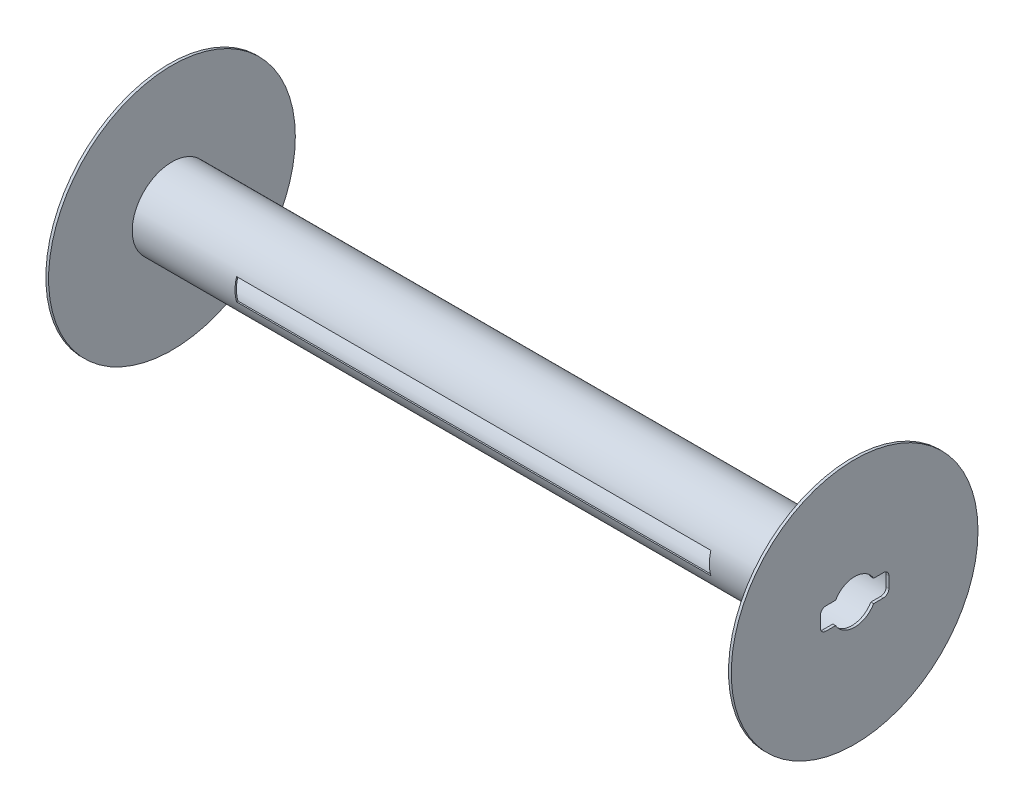
from build123d import *

# Parameters (mm, degrees)
SKETCH1_R           = 11.43
BOSS_EXTRUDE1_DEPTH = 0.254
SKETCH2_R           = 3.683
SKETCH2_R_2         = 3.556
BOSS_EXTRUDE2_DEPTH = 62.992
SKETCH3_R           = 11.43
BOSS_EXTRUDE3_DEPTH = 0.254
SKETCH5_W           = 43.942
SKETCH5_H           = 2.032
CUT_EXTRUDE1_DEPTH  = 2.794
SKETCH6_W           = 34.798
SKETCH6_H           = 1.980001403
CUT_EXTRUDE3_DEPTH  = 2.794
SKETCH7_R           = 2.032
CUT_EXTRUDE4_DEPTH  = 64.5


with BuildPart() as part:
    # Sketch1 → Boss-Extrude1 (new body)
    with BuildSketch(Plane(origin=(0, 0, 0), x_dir=(0, 0, -1), z_dir=(1, 0, 0))):
        Circle(SKETCH1_R)
    extrude(amount=BOSS_EXTRUDE1_DEPTH)

    # Sketch2 → Boss-Extrude2 (add)
    with BuildSketch(Plane(origin=(0.254, 0, 0), x_dir=(0, 0, -1), z_dir=(1, 0, 0))):
        Circle(SKETCH2_R)
        Circle(SKETCH2_R_2, mode=Mode.SUBTRACT)
    extrude(amount=BOSS_EXTRUDE2_DEPTH)

    # Sketch3 → Boss-Extrude3 (add)
    with BuildSketch(Plane(origin=(63.246, 0, 0), x_dir=(0, 0, -1), z_dir=(1, 0, 0))):
        Circle(SKETCH3_R)
    extrude(amount=BOSS_EXTRUDE3_DEPTH)

    # Sketch5 → Cut-Extrude1 (cut)
    with BuildSketch(Plane.XY.offset(3.683)):
        with Locations((31.75, 0)):
            Rectangle(SKETCH5_W, SKETCH5_H)
    extrude(amount=-CUT_EXTRUDE1_DEPTH, mode=Mode.SUBTRACT)

    # Sketch6 → Cut-Extrude3 (cut)
    with BuildSketch(Plane.XY.offset(-3.683)):
        with Locations((31.75, 0.025999298)):
            Rectangle(SKETCH6_W, SKETCH6_H)
    extrude(amount=CUT_EXTRUDE3_DEPTH, mode=Mode.SUBTRACT)

    # Sketch7 → Cut-Extrude4 (cut, through all)
    with BuildSketch(Plane(origin=(63.5, 0, 0), x_dir=(0, 0, -1), z_dir=(1, 0, 0))):
        with BuildLine():
            Line((-2.667, -1.016), (-1.75976362, -1.016))
            ThreePointArc((-1.75976362, -1.016), (-2.032, 0), (-1.75976362, 1.016))
            Line((-1.75976362, 1.016), (-2.667, 1.016))
            ThreePointArc((-2.667, 1.016), (-3.026210245, 0.867210245), (-3.175, 0.508))
            Line((-3.175, 0.508), (-3.175, -0.508))
            ThreePointArc((-3.175, -0.508), (-3.026210245, -0.867210245), (-2.667, -1.016))
        make_face()
        with BuildLine():
            ThreePointArc((2.667, -1.016), (3.026210245, -0.867210245), (3.175, -0.508))
            Line((3.175, -0.508), (3.175, 0.508))
            ThreePointArc((3.175, 0.508), (3.026210245, 0.867210245), (2.667, 1.016))
            Line((2.667, 1.016), (1.75976362, 1.016))
            ThreePointArc((1.75976362, 1.016), (1.962761279, 0.5259203), (2.032, 0))
            ThreePointArc((2.032, 0), (1.962761279, -0.5259203), (1.75976362, -1.016))
            Line((1.75976362, -1.016), (2.667, -1.016))
        make_face()
        Circle(SKETCH7_R)
    extrude(amount=-CUT_EXTRUDE4_DEPTH, mode=Mode.SUBTRACT)


solid = part.part
